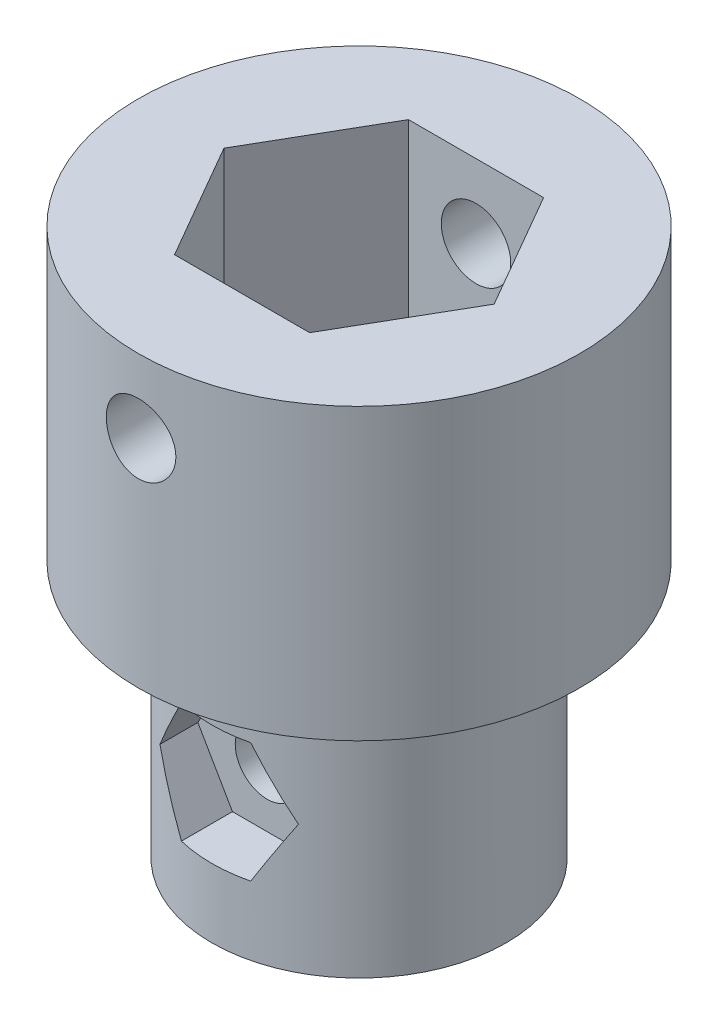
from build123d import *

# Parameters (mm, degrees)
SKETCH1_R               = 7.62
BOSS_EXTRUDE1_DEPTH     = 10
CUT_EXTRUDE1_DEPTH      = 7.62
SKETCH4_R               = 2.75
CUT_EXTRUDE2_DEPTH      = 9.5
SKETCH5_R               = 5.08
BOSS_EXTRUDE2_DEPTH     = 8.89
CUT_EXTRUDE3_REACH      = 20.89
SKETCH6_R               = 2.08915
SKETCH7_R               = 1.1
CUT_EXTRUDE4_DEPTH      = 8.89
CUT_EXTRUDE4_DEPTH_BACK = 8.89
SKETCH8_R               = 1.2
CUT_EXTRUDE5_DEPTH      = 8.89
CUT_EXTRUDE5_DEPTH_BACK = 8.89
CUT_EXTRUDE6_DEPTH      = 1.905


with BuildPart() as part:
    # Sketch1 → Boss-Extrude1 (new body)
    with BuildSketch(Plane(origin=(0, 0, 0), x_dir=(1, 0, 0), z_dir=(0, 1, 0))):
        Circle(SKETCH1_R)
    extrude(amount=BOSS_EXTRUDE1_DEPTH)

    # Sketch2 → Cut-Extrude1 (cut)
    with BuildSketch(Plane(origin=(0, 10, 0), x_dir=(1, 0, 0), z_dir=(0, 1, 0))):
        Polygon((-2.331686797, 4.0386), (-4.663373594, 0), (-2.331686797, -4.0386), (2.331686797, -4.0386), (4.663373594, 0), (2.331686797, 4.0386), align=None)
    extrude(amount=-CUT_EXTRUDE1_DEPTH, mode=Mode.SUBTRACT)

    # Sketch4 → Cut-Extrude2 (cut)
    with BuildSketch(Plane(origin=(0, 2.38, 0), x_dir=(1, 0, 0), z_dir=(0, 1, 0))):
        Circle(SKETCH4_R)
    extrude(amount=-CUT_EXTRUDE2_DEPTH, mode=Mode.SUBTRACT)

    # Sketch5 → Boss-Extrude2 (add)
    with BuildSketch(Plane(origin=(0, 0, 0), x_dir=(-1, 0, 0), z_dir=(0, -1, 0))):
        Circle(SKETCH5_R)
    extrude(amount=BOSS_EXTRUDE2_DEPTH)

    # Sketch6 → Cut-Extrude3 (cut, up to next)
    with BuildSketch(Plane(origin=(0, -8.89, 0), x_dir=(-1, 0, 0), z_dir=(0, -1, 0)), mode=Mode.PRIVATE) as cut_extrude3_sk1:
        Circle(SKETCH6_R)
    cut_extrude3_tool1 = extrude(cut_extrude3_sk1.sketch, amount=-CUT_EXTRUDE3_REACH, mode=Mode.PRIVATE) & part.part
    add(cut_extrude3_tool1.solids().sort_by_distance((0, -8.89, 0))[0], mode=Mode.SUBTRACT)

    # Sketch7 → Cut-Extrude4 (cut, two sides)
    with BuildSketch(Plane.XY) as cut_extrude4_sk:
        with Locations((0, -4.445)):
            Circle(SKETCH7_R)
    extrude(amount=CUT_EXTRUDE4_DEPTH, mode=Mode.SUBTRACT)
    extrude(cut_extrude4_sk.sketch, amount=-CUT_EXTRUDE4_DEPTH_BACK, mode=Mode.SUBTRACT)

    # Sketch8 → Cut-Extrude5 (cut, two sides)
    with BuildSketch(Plane.XY) as cut_extrude5_sk:
        with Locations((0, 7.46)):
            Circle(SKETCH8_R)
    extrude(amount=CUT_EXTRUDE5_DEPTH, mode=Mode.SUBTRACT)
    extrude(cut_extrude5_sk.sketch, amount=-CUT_EXTRUDE5_DEPTH_BACK, mode=Mode.SUBTRACT)

    # Sketch9 → Cut-Extrude6 (cut)
    with BuildSketch(Plane.XY.offset(5.08)):
        Polygon((1.195172792, -2.3749), (-1.195172792, -2.3749), (-2.390345584, -4.445), (-1.195172792, -6.5151), (1.195172792, -6.5151), (2.390345584, -4.445), align=None)
    extrude(amount=-CUT_EXTRUDE6_DEPTH, mode=Mode.SUBTRACT)


solid = part.part
